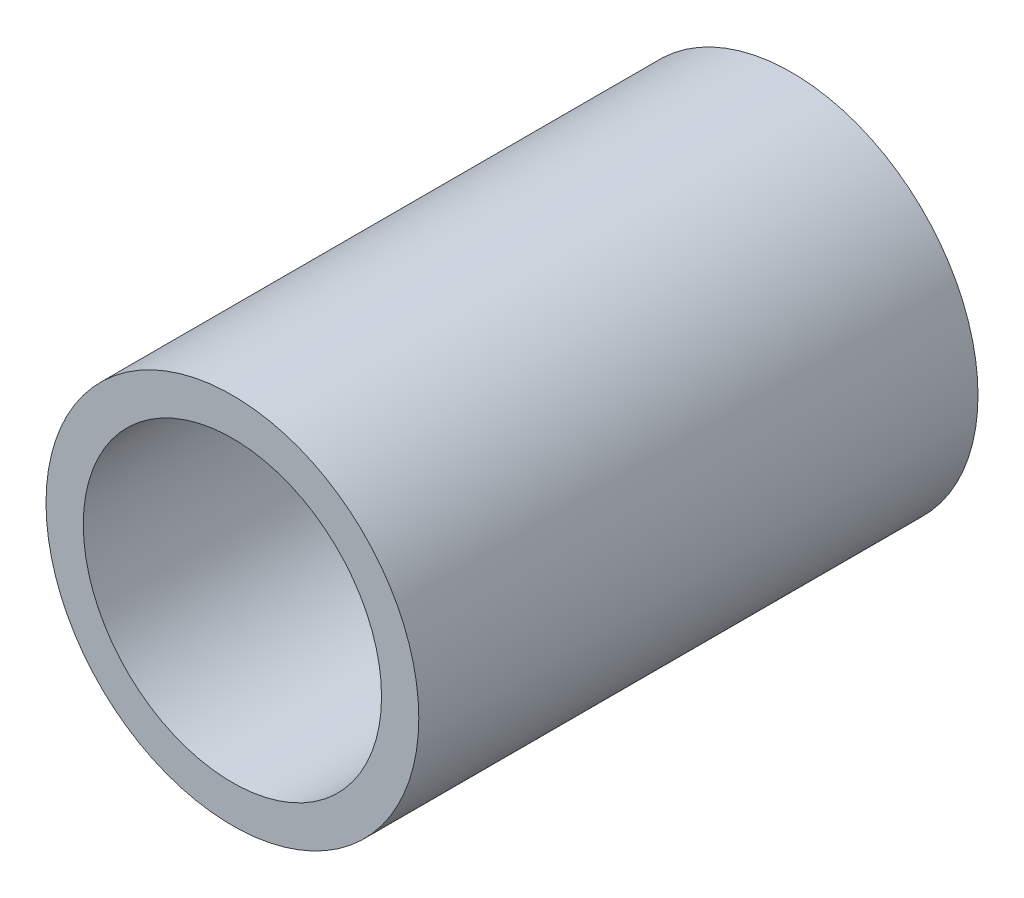
from build123d import *

# Parameters (mm, degrees)
SKETCH1_R           = 5
BOSS_EXTRUDE1_DEPTH = 15
SHELL5_T            = -1


with BuildPart() as part:
    # Sketch1 → Boss-Extrude1 (new body)
    with BuildSketch(Plane.XY):
        Circle(SKETCH1_R)
    extrude(amount=-BOSS_EXTRUDE1_DEPTH)

    # Shell5
    shell5_openings = [part.faces().sort_by_distance(p)[0] for p in [
        (0, 0, 0),
    ]]
    offset(amount=SHELL5_T, openings=shell5_openings, kind=Kind.INTERSECTION)


solid = part.part
